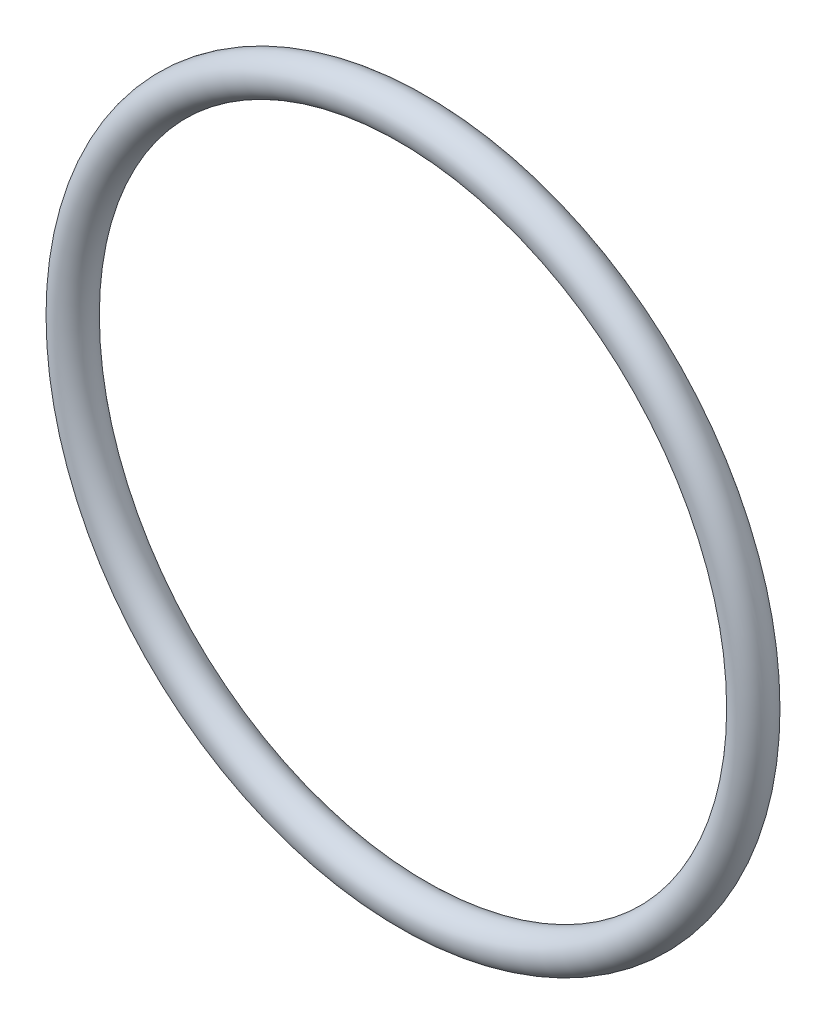
from build123d import *

# Parameters (mm, degrees)
SKETCH_1_R = 2.5


with BuildPart() as part:
    # 草图1 → 旋转1 (revolve)
    with BuildSketch(Plane(origin=(1.604815493, 9.101360931, 0), x_dir=(0.984807753, -0.173648178, 0), z_dir=(-0.173648178, -0.984807753, 0))):
        with Locations((39.254369802, 30.893736042)):
            Circle(SKETCH_1_R)
    revolve(axis=Axis((-4.145535771, 10.115302746, 27.184801913), (0, 0, -1)))


solid = part.part
